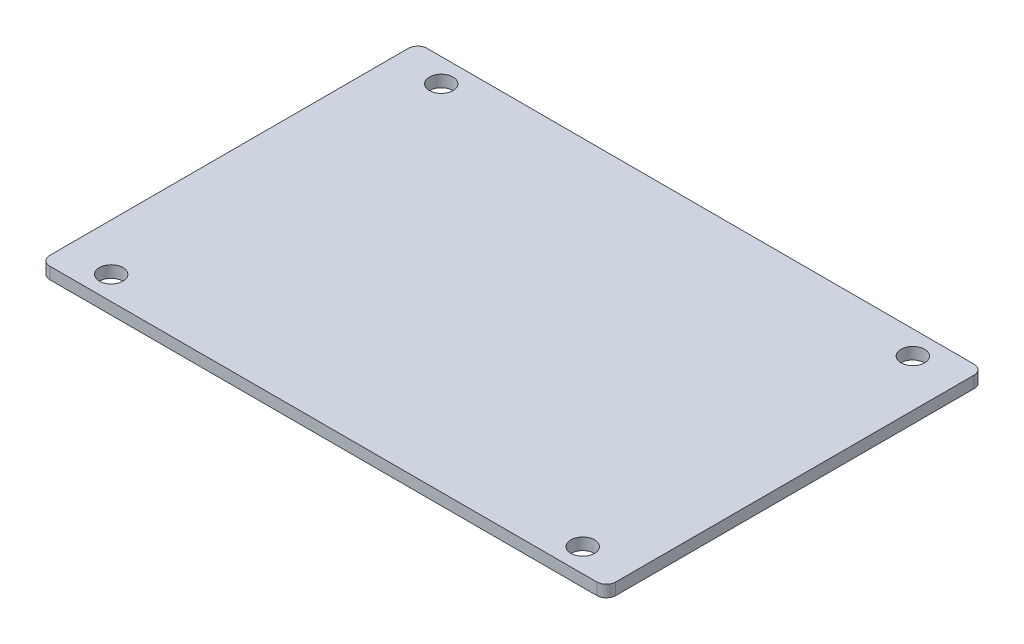
from build123d import *

# Parameters (mm, degrees)
BOSS_EXTRUDE1_DEPTH            = 3.175
HOLE_FOR_10_300_SC_NUTS_SP_1_D = 6.35


with BuildPart() as part:
    # Sketch1 → Boss-Extrude1 (new body)
    with BuildSketch(Plane(origin=(0, 0, 0), x_dir=(1, 0, 0), z_dir=(0, 1, 0))):
        with BuildLine():
            Line((-64.865326877, 53.014043584), (82.454673123, 53.014043584))
            ThreePointArc((82.454673123, 53.014043584), (84.250724348, 52.270094808), (84.994673123, 50.474043584))
            Line((84.994673123, 50.474043584), (84.994673123, -46.045956416))
            ThreePointArc((84.994673123, -46.045956416), (84.250724348, -47.842007641), (82.454673123, -48.585956416))
            Line((82.454673123, -48.585956416), (-64.865326877, -48.585956416))
            ThreePointArc((-64.865326877, -48.585956416), (-66.661378101, -47.842007641), (-67.405326877, -46.045956416))
            Line((-67.405326877, -46.045956416), (-67.405326877, 50.474043584))
            ThreePointArc((-67.405326877, 50.474043584), (-66.661378101, 52.270094808), (-64.865326877, 53.014043584))
        make_face()
    extrude(amount=BOSS_EXTRUDE1_DEPTH)

    # Hole for #10 300® SC Nuts (SP)1 (through all)
    with Locations(Plane(origin=(0, 0, 0), x_dir=(-1, 0, 0), z_dir=(0, -1, 0))):
        with Locations((-72.294673123, 46.664043584), (-72.294673123, -42.235956416), (54.705326877, -42.235956416), (54.705326877, 46.664043584)):
            Hole(HOLE_FOR_10_300_SC_NUTS_SP_1_D / 2)


solid = part.part
